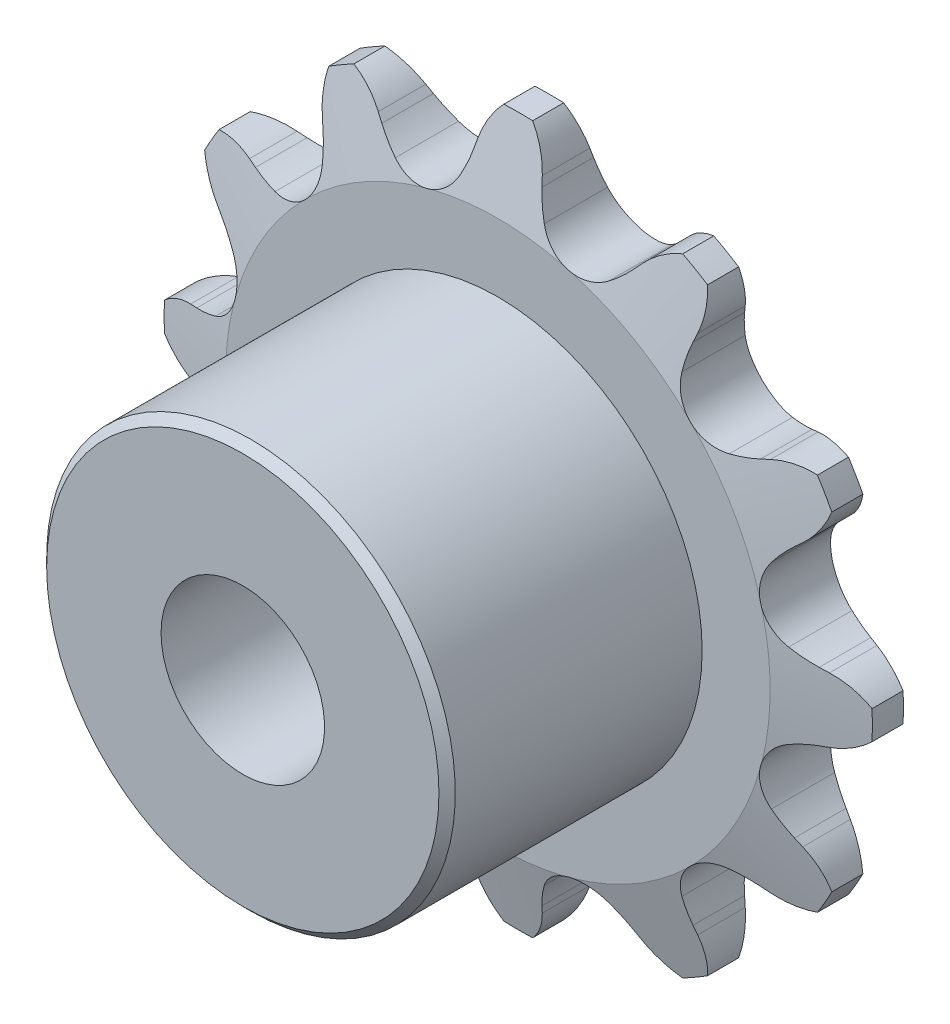
from build123d import *

# Parameters (mm, degrees)
CUT_EXTRUDE1_DEPTH      = 20.501564491
CIRPATTERN1_COUNT       = 12
BOSS_EXTRUDE1_START     = 1.397
SKETCH2_R               = 7.9375
BOSS_EXTRUDE1_DEPTH     = 9.906
CUT_EXTRUDE2_DEPTH      = 23.497049209
CUT_EXTRUDE2_DEPTH_BACK = 23.497049209
SKETCH3_R               = 3.175
SKETCH4_W               = 2.0955
SKETCH4_H               = 5.461


with BuildPart() as part:
    # Sketch1 → Revolve1 (revolve)
    with BuildSketch(Plane(origin=(0, 0, 0), x_dir=(0, 0, -1), z_dir=(1, 0, 0)), mode=Mode.PRIVATE) as revolve1_sk:
        Polygon((1.397, 0), (-1.397, 0), (-1.397, 10.579261314), (-0.60325, 13.754261314), (0.60325, 13.754261314), (1.397, 10.579261314), align=None)
    revolve(revolve1_sk.sketch.rotate(Axis((0, 0, -1.397), (0, 0, 1)), 90), axis=Axis((0, 0, -1.397), (0, 0, 1)))

    # Sketch0 → Cut-Extrude1 (cut, symmetric)
    with BuildSketch(Plane.XY):
        with BuildLine():
            Line((5.117617163, -11.371857705), (4.901148654, -11.128614009))
            ThreePointArc((4.901148654, -11.128614009), (4.544359831, -10.771825186), (4.148562832, -10.458869496))
            ThreePointArc((4.148562832, -10.458869496), (2.7356922, -10.209742283), (1.636673946, -11.131928094))
            ThreePointArc((1.636673946, -11.131928094), (1.450381536, -11.600854172), (1.319787763, -12.088236768))
            Line((1.319787763, -12.088236768), (1.253942383, -12.407126242))
            ThreePointArc((1.253942383, -12.407126242), (0.161394669, -14.090046377), (-1.782387416, -14.587632443))
            ThreePointArc((-1.782387416, -14.587632443), (3.803635588, -14.195361268), (8.837409003, -11.742066569))
            ThreePointArc((8.837409003, -11.742066569), (6.905251305, -12.283035437), (5.117617163, -11.371857705))
        make_face()
    cut_extrude1 = extrude(amount=CUT_EXTRUDE1_DEPTH, both=True, mode=Mode.SUBTRACT)

    # CirPattern1: Cut-Extrude1 ×12 about axis
    cirpattern1_axis = Axis((0, 0, 0), (0, 0, 1))
    for i in range(1, CIRPATTERN1_COUNT):
        add(cut_extrude1.rotate(cirpattern1_axis, i * 360 / CIRPATTERN1_COUNT), mode=Mode.SUBTRACT)

    # Sketch2 → Boss-Extrude1 (add)
    with BuildSketch(Plane.XY.offset(BOSS_EXTRUDE1_START)):
        Circle(SKETCH2_R)
    extrude(amount=BOSS_EXTRUDE1_DEPTH)

    # Sketch3 → Cut-Extrude2 (cut, two sides: drawn at the far end of the back side and taken through both)
    with BuildSketch(Plane.XY.offset(-CUT_EXTRUDE2_DEPTH_BACK)):
        with Locations(Location((0, 0, 0), (0, 0, 180))):
            Circle(SKETCH3_R)
    extrude(amount=CUT_EXTRUDE2_DEPTH + CUT_EXTRUDE2_DEPTH_BACK, mode=Mode.SUBTRACT)

    # Sketch4 → Cut-Revolve1 (revolve, cut)
    with BuildSketch(Plane(origin=(0, 0, 0), x_dir=(0, 0, -1), z_dir=(1, 0, 0))):
        Polygon((-11.303, 7.9375), (-11.303, 7.62), (-10.9855, 7.9375), align=None)
        with Locations((-2.44475, 11.023761314)):
            Rectangle(SKETCH4_W, SKETCH4_H)
    revolve(axis=Axis((0, 0, -1.397), (0, 0, 1)), mode=Mode.SUBTRACT)


solid = part.part
